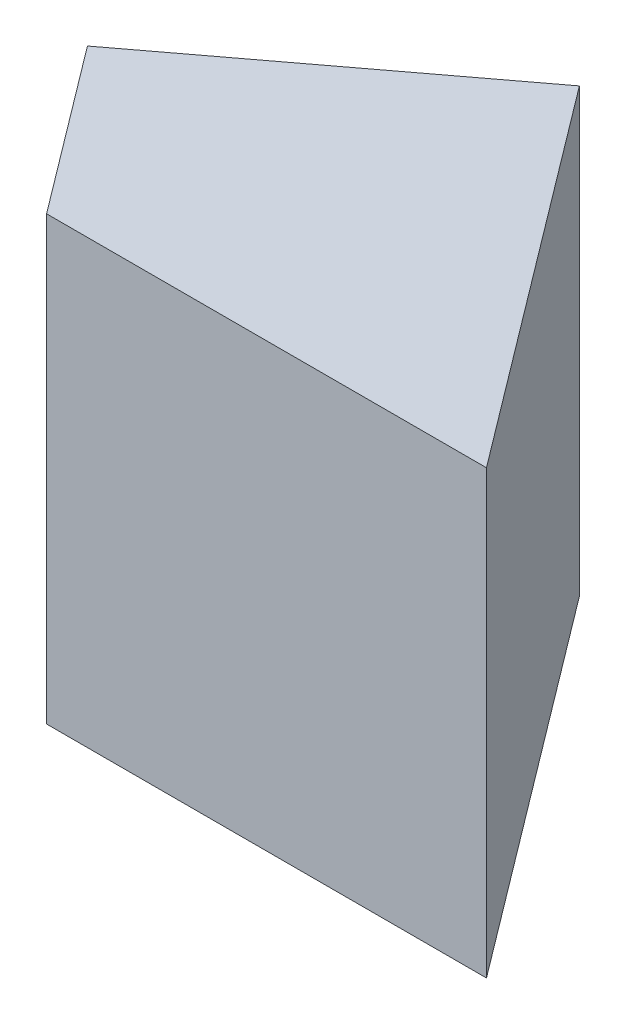
from build123d import *

# Parameters (mm, degrees)
EXTRUDE_1_DEPTH = 20


with BuildPart() as part:
    # Эскиз1 → Бобышка-Вытянуть1 (new body)
    with BuildSketch(Plane(origin=(0, -10, 0), x_dir=(1, 0, 0), z_dir=(0, 1, 0))):
        Polygon((-10.927691668, 0), (1.770612942, 9.568858868), (14.633780577, -7.501141132), (-5.275176387, -7.501141132), align=None)
    extrude(amount=EXTRUDE_1_DEPTH)


solid = part.part
